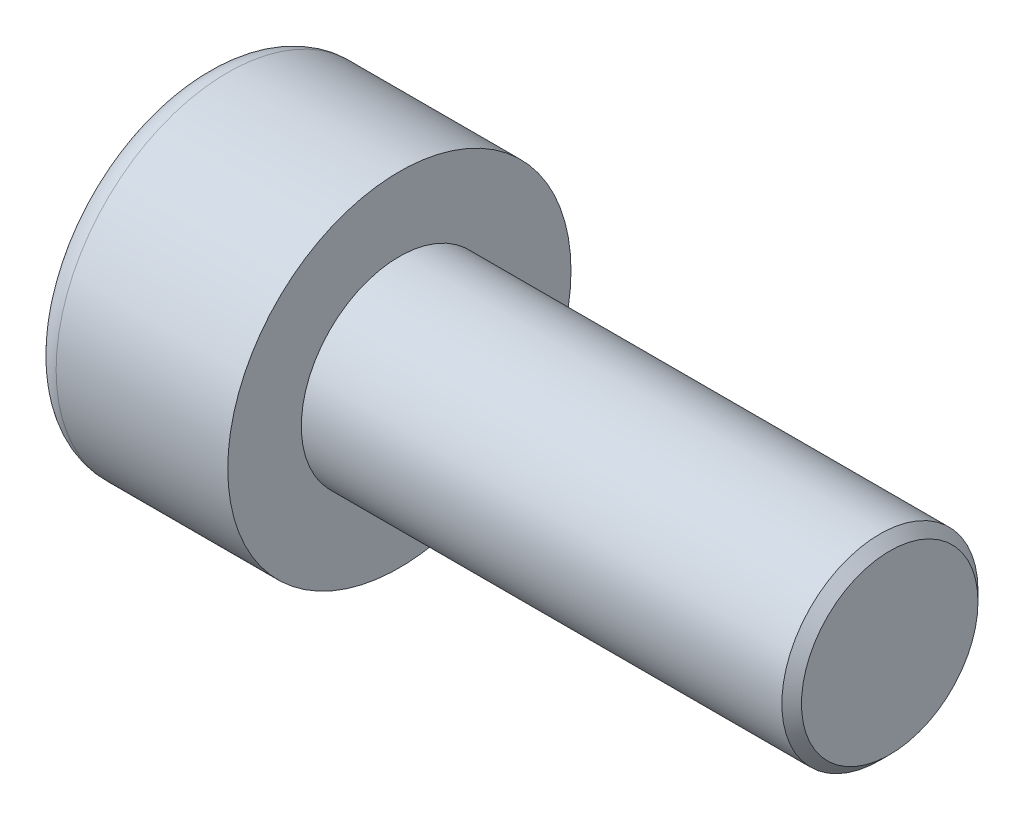
from build123d import *

# Parameters (mm, degrees)
SKETCH1_R           = 3.5
BASEHEAD_DEPTH      = 4
SKETCH2_R           = 2
BASEBODY_DEPTH      = 10
HEXAGONSOCKET_DEPTH = 2
TOPFILLET_R         = 0.5
CHAMFER1_SIZE       = 0.2


with BuildPart() as part:
    # Sketch1 → BaseHead (new body)
    with BuildSketch(Plane(origin=(0, 0, 0), x_dir=(0, 0, -1), z_dir=(1, 0, 0))):
        Circle(SKETCH1_R)
    extrude(amount=BASEHEAD_DEPTH)

    # Sketch2 → BaseBody (add)
    with BuildSketch(Plane(origin=(4, 0, 0), x_dir=(0, 0, -1), z_dir=(1, 0, 0))):
        Circle(SKETCH2_R)
    extrude(amount=BASEBODY_DEPTH)

    # Sketch3 → HexagonSocket (cut)
    with BuildSketch(Plane(origin=(0, 0, 0), x_dir=(0, 0, -1), z_dir=(1, 0, 0))):
        Polygon((1.732050808, 0), (0.866025404, 1.5), (-0.866025404, 1.5), (-1.732050808, 0), (-0.866025404, -1.5), (0.866025404, -1.5), align=None)
    extrude(amount=HEXAGONSOCKET_DEPTH, mode=Mode.SUBTRACT)

    # Sketch4 → Cut-Revolve1 (revolve, cut)
    with BuildSketch(Plane(origin=(-4.19613823, 0.75, 0), x_dir=(-1, 0, 0), z_dir=(0, 0, 1))):
        Polygon((-6.19613823, 2.25), (-7.062163633, 0.75), (-6.19613823, 0.75), align=None)
    revolve(axis=Axis((0.838992387, 0, 0), (-1, 0, 0)), mode=Mode.SUBTRACT)

    # TopFillet
    topfillet_edges = [part.edges().sort_by_distance(p)[0] for p in [
        (0, 0, 3.5),
    ]]
    fillet(topfillet_edges, radius=TOPFILLET_R)

    # Chamfer1
    chamfer1_edges = [part.edges().sort_by_distance(p)[0] for p in [
        (14, 0, 2),
    ]]
    chamfer(chamfer1_edges, length=CHAMFER1_SIZE)


solid = part.part
